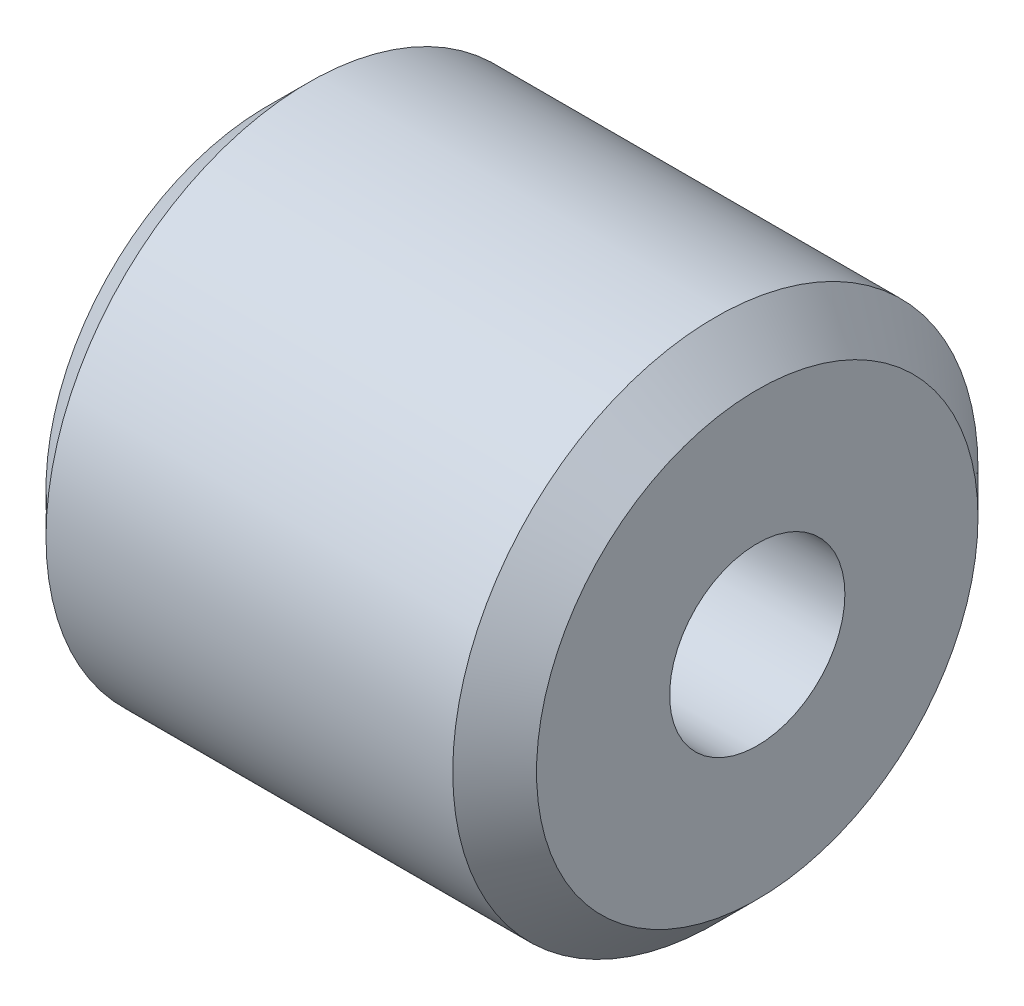
from build123d import *

# Parameters (mm, degrees)
SKETCH1_R           = 4.765
SKETCH1_R_2         = 1.59
BOSS_EXTRUDE1_DEPTH = 4.45
CHAMFER1_SIZE       = 0.76


with BuildPart() as part:
    # Sketch1 → Boss-Extrude1 (new body, symmetric)
    with BuildSketch(Plane(origin=(0, 0, 0), x_dir=(0, 0, -1), z_dir=(1, 0, 0))):
        Circle(SKETCH1_R)
        Circle(SKETCH1_R_2, mode=Mode.SUBTRACT)
    extrude(amount=BOSS_EXTRUDE1_DEPTH, both=True)

    # Chamfer1
    chamfer1_edges = [part.edges().sort_by_distance(p)[0] for p in [
        (-4.45, 0, 4.765),
        (4.45, 0, 4.765),
    ]]
    chamfer(chamfer1_edges, length=CHAMFER1_SIZE)


solid = part.part
